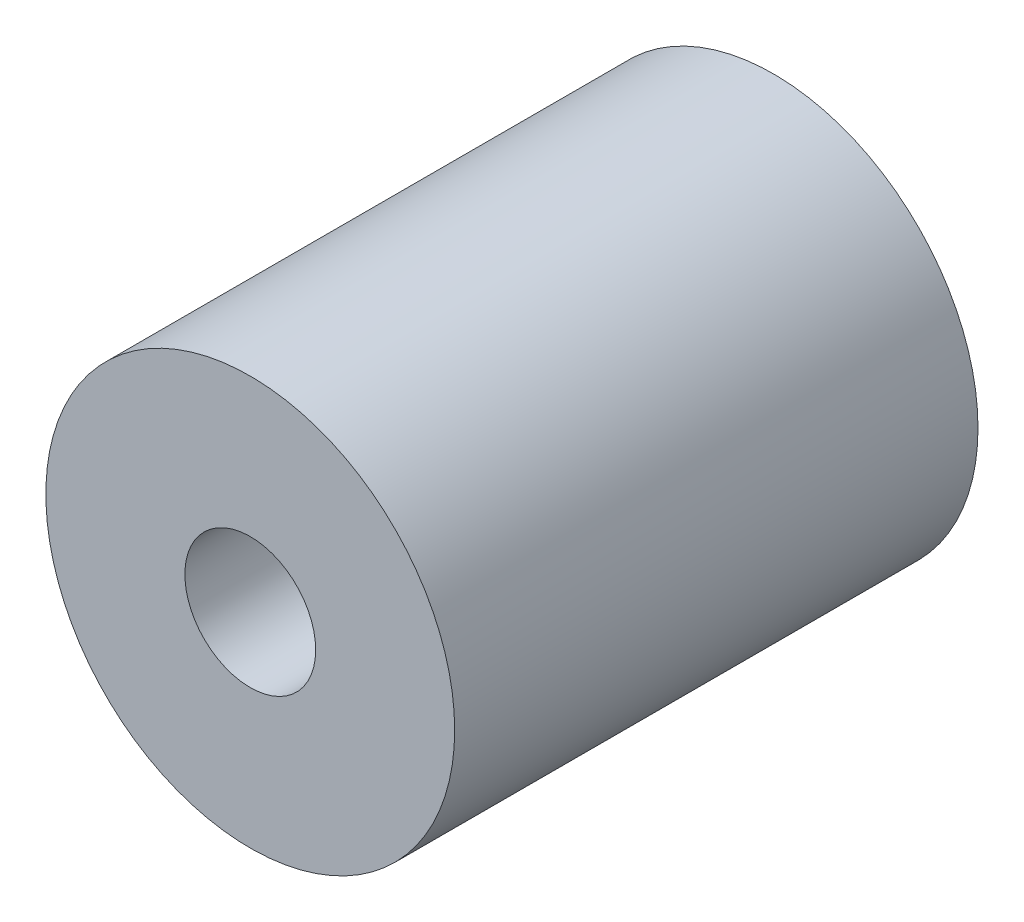
from build123d import *

# Parameters (mm, degrees)
ESQUISSE1_R          = 12.5
ESQUISSE1_R_2        = 4
BASE_EXTRUSION_DEPTH = 32


with BuildPart() as part:
    # Esquisse1 → Base-Extrusion (new body)
    with BuildSketch(Plane.XY):
        Circle(ESQUISSE1_R)
        Circle(ESQUISSE1_R_2, mode=Mode.SUBTRACT)
    extrude(amount=BASE_EXTRUSION_DEPTH)


solid = part.part
